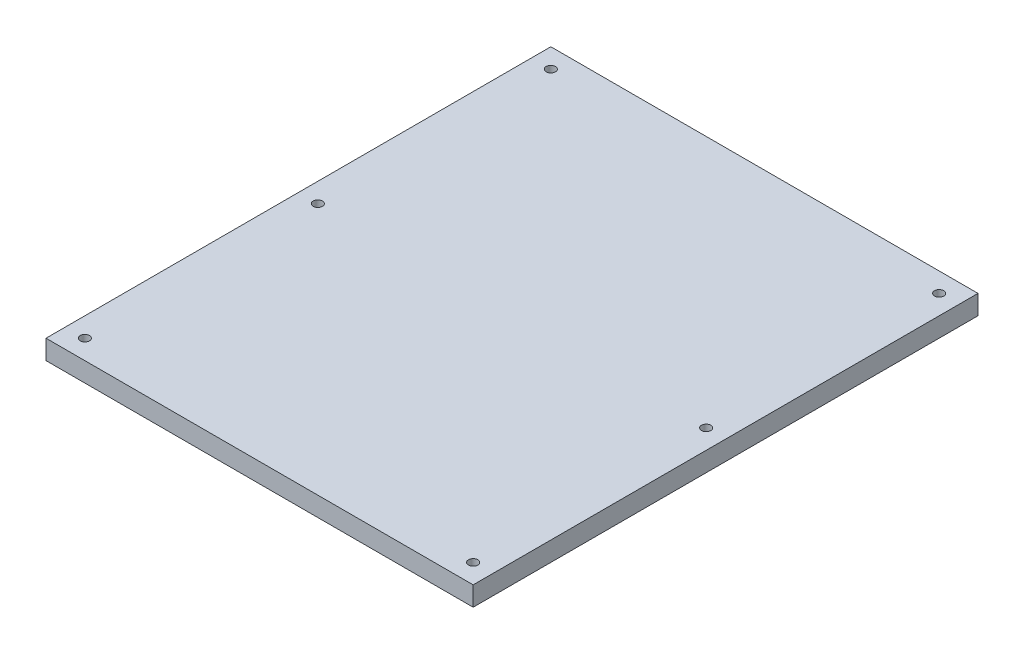
from build123d import *

# Parameters (mm, degrees)
SKETCH1_W          = 139.7
SKETCH1_H          = 165.1
EXTRUDE1_DEPTH     = 6.35
SKETCH2_R          = 1.524
CUT_EXTRUDE1_DEPTH = 7.35


with BuildPart() as part:
    # Sketch1 → Extrude1 (new body)
    with BuildSketch(Plane(origin=(0, 0, 0), x_dir=(1, 0, 0), z_dir=(0, 1, 0))):
        with Locations((26.351386865, -57.820467751)):
            Rectangle(SKETCH1_W, SKETCH1_H)
    extrude(amount=EXTRUDE1_DEPTH)

    # Sketch2 → Cut-Extrude1 (cut, through all)
    with BuildSketch(Plane(origin=(0, 6.35, 0), x_dir=(1, 0, 0), z_dir=(0, 1, 0))):
        with Locations(Location((-37.148613135, 18.379532249, 0), (0, 0, 270))):  # turned: the seam where the file's is
            Circle(SKETCH2_R)
        with Locations(Location((-37.148613135, -57.820467751, 0), (0, 0, 270))):  # turned: the seam where the file's is
            Circle(SKETCH2_R)
        with Locations(Location((89.851386865, 18.379532249, 0), (0, 0, 270))):  # turned: the seam where the file's is
            Circle(SKETCH2_R)
        with Locations(Location((89.851386865, -134.020467751, 0), (0, 0, 270))):  # turned: the seam where the file's is
            Circle(SKETCH2_R)
        with Locations(Location((89.851386865, -57.820467751, 0), (0, 0, 270))):  # turned: the seam where the file's is
            Circle(SKETCH2_R)
        with Locations(Location((-37.148613135, -134.020467751, 0), (0, 0, 270))):  # turned: the seam where the file's is
            Circle(SKETCH2_R)
    extrude(amount=-CUT_EXTRUDE1_DEPTH, mode=Mode.SUBTRACT)


solid = part.part
